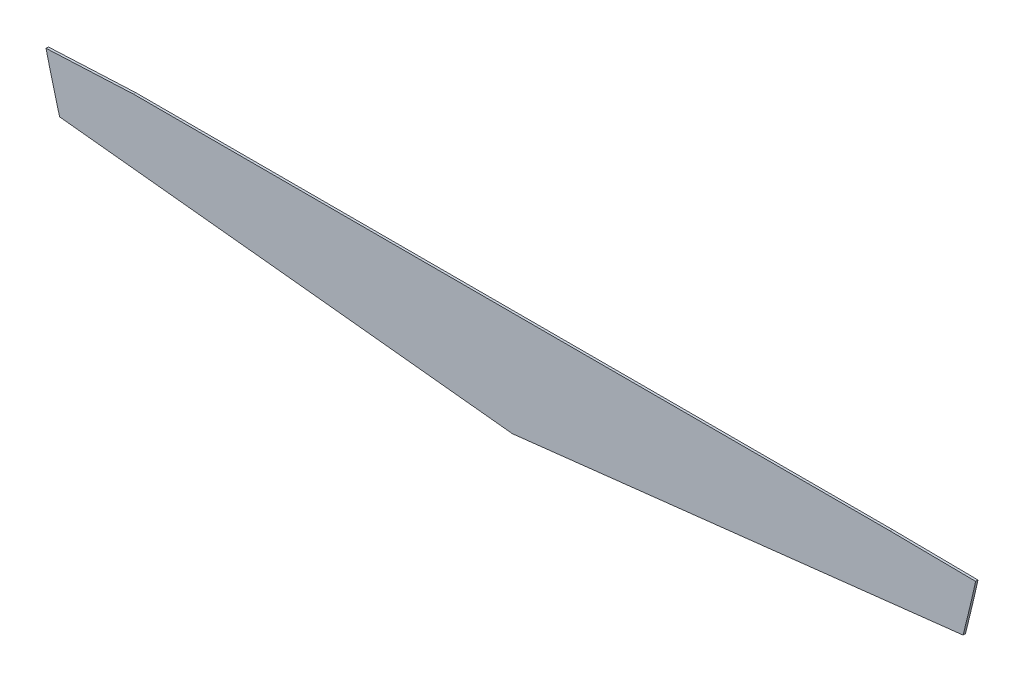
from build123d import *

# Parameters (mm, degrees)
SALIENTE_EXTRUIR1_DEPTH = 0.1


with BuildPart() as part:
    # Model → Saliente-Extruir1 (new body)
    with BuildSketch(Plane.XY):
        with BuildLine():
            Line((47.900286295, -3.880714535), (15.900286295, -3.880714535))
            Line((15.900286295, -3.880714535), (12.202555869, -4.052676889))
            ThreePointArc((12.202555869, -4.052676889), (12.48180991, -5.167779291), (12.778578315, -6.278348831))
            Line((12.778578315, -6.278348831), (31.925658705, -8.308398583))
            Line((31.925658705, -8.308398583), (50.990379009, -6.152892242))
            ThreePointArc((50.990379009, -6.152892242), (51.263698747, -5.03797547), (51.52136497, -3.919337367))
            Line((51.52136497, -3.919337367), (47.900286295, -3.880714535))
        make_face()
    extrude(amount=SALIENTE_EXTRUIR1_DEPTH)


solid = part.part
